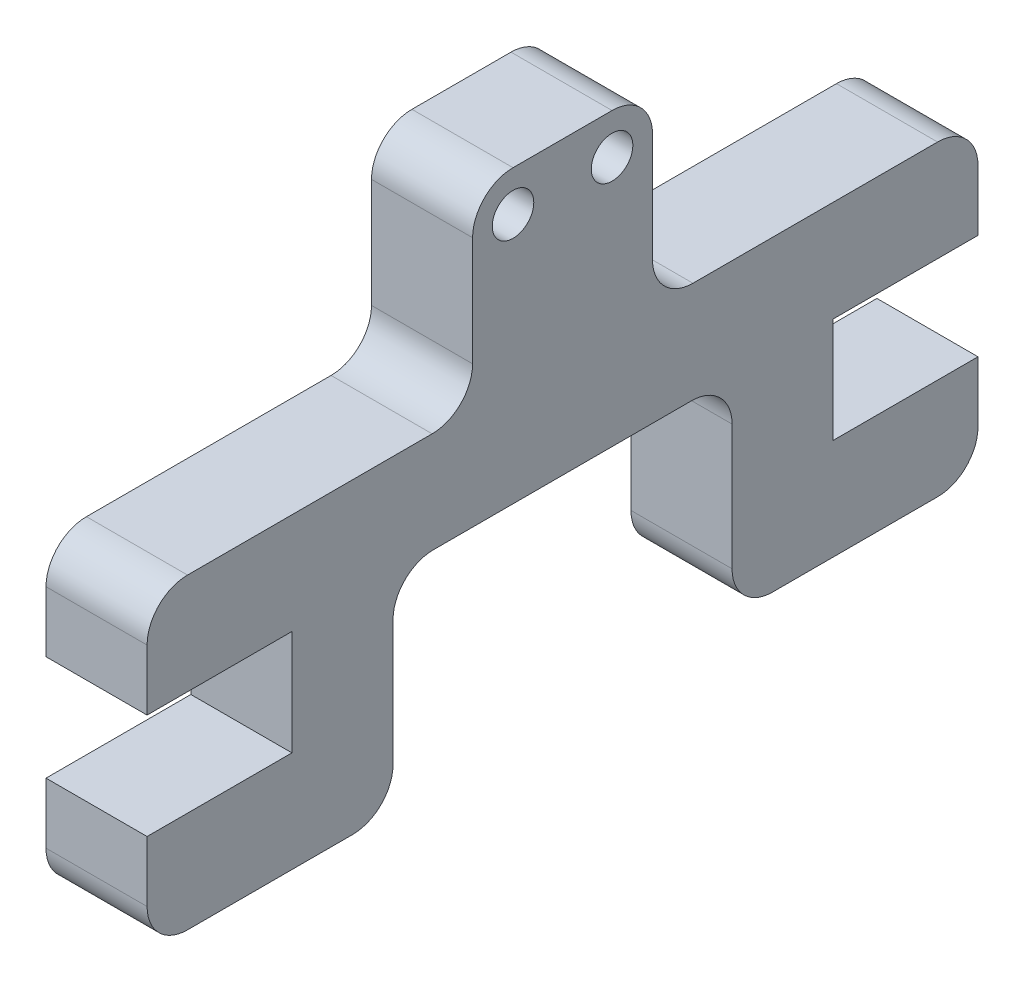
from build123d import *

# Parameters (mm, degrees)
BOSS_EXTRUDE1_DEPTH = 10
SKETCH3_R           = 2.055
CUT_EXTRUDE1_DEPTH  = 11
BOSS_EXTRUDE2_DEPTH = 10
FILLET1_R           = 4
FILLET2_R           = 4


with BuildPart() as part:
    # Sketch1 → Boss-Extrude1 (new body)
    with BuildSketch(Plane(origin=(0, 0, 0), x_dir=(0, 0, -1), z_dir=(1, 0, 0))):
        Polygon((17.8, -18.8), (50, -18.8), (50, -28.8), (-32.2, -28.8), (-32.2, -18.8), (0, -18.8), (0, 0), (17.8, 0), align=None)
    extrude(amount=BOSS_EXTRUDE1_DEPTH)

    # Sketch3 → Cut-Extrude1 (cut, through all)
    with BuildSketch(Plane(origin=(10, 0, 0), x_dir=(0, 0, -1), z_dir=(1, 0, 0))):
        with Locations((4, -4)):
            Circle(SKETCH3_R)
        with Locations((13.8, -4)):
            Circle(SKETCH3_R)
    extrude(amount=-CUT_EXTRUDE1_DEPTH, mode=Mode.SUBTRACT)

    # Sketch4 → Boss-Extrude2 (add)
    with BuildSketch(Plane(origin=(10, 0, 0), x_dir=(0, 0, -1), z_dir=(1, 0, 0))):
        Polygon((-17.87, -28.8), (-17.87, -39.2), (-32.2, -39.2), (-32.2, -49.2), (-7.87, -49.2), (-7.87, -28.8), align=None)
        Polygon((35.67, -28.8), (25.67, -28.8), (25.67, -49.2), (50, -49.2), (50, -39.2), (35.67, -39.2), align=None)
    extrude(amount=-BOSS_EXTRUDE2_DEPTH)

    # Fillet1
    fillet1_edges = [part.edges().sort_by_distance(p)[0] for p in [
        (5, 0, 0),
        (5, 0, -17.8),
    ]]
    fillet(fillet1_edges, radius=FILLET1_R)

    # Fillet2
    fillet2_edges = [part.edges().sort_by_distance(p)[0] for p in [
        (5, -18.8, -17.8),
        (5, -18.8, -50),
        (5, -18.8, 32.2),
        (5, -18.8, 0),
        (5, -49.2, 32.2),
        (5, -49.2, 7.87),
        (5, -28.8, 7.87),
        (5, -28.8, -25.67),
        (5, -49.2, -25.67),
        (5, -49.2, -50),
    ]]
    fillet(fillet2_edges, radius=FILLET2_R)


solid = part.part
